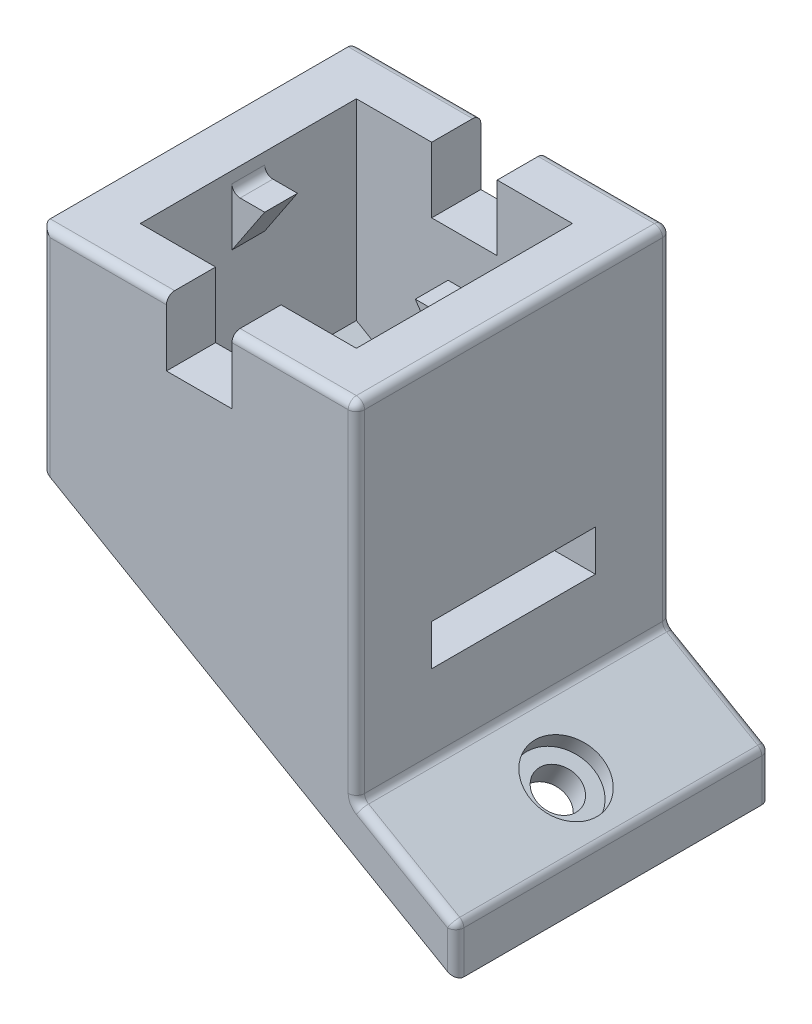
from build123d import *

# Parameters (mm, degrees)
SKETCH1_W           = 19.2
SKETCH1_H           = 19.2
SKETCH1_W_2         = 13.2
SKETCH1_H_2         = 13.2
BOSS_EXTRUDE1_DEPTH = 30
CUT_EXTRUDE1_DEPTH  = 30
BOSS_EXTRUDE2_DEPTH = 19.2
SKETCH4_R           = 1.28
CUT_EXTRUDE2_DEPTH  = 30
SKETCH5_R           = 2.18
CUT_EXTRUDE3_DEPTH  = 1
SKETCH6_W           = 10
SKETCH6_H           = 2.5
CUT_EXTRUDE4_DEPTH  = 3
BOSS_EXTRUDE3_DEPTH = 1
SKETCH8_W           = 4
SKETCH8_H           = 3
CUT_EXTRUDE5_DEPTH  = 4
FILLET1_R           = 0.5
FILLET2_R           = 0.5


with BuildPart() as part:
    # Sketch1 → Boss-Extrude1 (new body)
    with BuildSketch(Plane(origin=(0, 0, 0), x_dir=(1, 0, 0), z_dir=(0, 1, 0))):
        Rectangle(SKETCH1_W, SKETCH1_H)
        Rectangle(SKETCH1_W_2, SKETCH1_H_2, mode=Mode.SUBTRACT)
    extrude(amount=-BOSS_EXTRUDE1_DEPTH)

    # Sketch2 → Cut-Extrude1 (cut)
    with BuildSketch(Plane.XY.offset(9.6)):
        Polygon((-9.6, -30), (-9.6, -10), (25.041016151, -30), align=None)
    extrude(amount=-CUT_EXTRUDE1_DEPTH, mode=Mode.SUBTRACT)

    # Sketch3 → Boss-Extrude2 (add)
    with BuildSketch(Plane.XY.offset(9.6)):
        Polygon((-9.6, -10), (-9.6, -12.886751346), (15.662177826, -27.471876514), (15.662177826, -24.585125168), align=None)
    extrude(amount=-BOSS_EXTRUDE2_DEPTH)

    # Sketch4 → Cut-Extrude2 (cut)
    with BuildSketch(Plane(origin=(-6.730127019, -11.656921938, 0), x_dir=(0.866025404, -0.5, 0), z_dir=(0.5, 0.866025404, 0))):
        with Locations(Location((22.558741962, 0, 0), (0, 0, 180))):  # turned: the seam where the file's is
            Circle(SKETCH4_R)
    extrude(amount=-CUT_EXTRUDE2_DEPTH, mode=Mode.SUBTRACT)

    # Sketch5 → Cut-Extrude3 (cut)
    with BuildSketch(Plane(origin=(-6.730127019, -11.656921938, 0), x_dir=(0.866025404, -0.5, 0), z_dir=(0.5, 0.866025404, 0))):
        with Locations(Location((22.558741962, 0, 0), (0, 0, 180))):  # turned: the seam where the file's is
            Circle(SKETCH5_R)
    extrude(amount=-CUT_EXTRUDE3_DEPTH, mode=Mode.SUBTRACT)

    # Sketch6 → Cut-Extrude4 (cut)
    with BuildSketch(Plane(origin=(9.6, 0, 0), x_dir=(0, 0, -1), z_dir=(1, 0, 0))):
        with Locations((0, -15)):
            Rectangle(SKETCH6_W, SKETCH6_H)
    extrude(amount=-CUT_EXTRUDE4_DEPTH, mode=Mode.SUBTRACT)

    # Sketch7 → Boss-Extrude3 (add, symmetric)
    with BuildSketch(Plane.XY):
        Polygon((-6.6, -4.2), (-6.6, -1.2), (-4.6, -1.2), align=None)
        Polygon((6.6, -1.2), (4.6, -1.2), (6.6, -4.2), align=None)
    extrude(amount=BOSS_EXTRUDE3_DEPTH, both=True)

    # Sketch8 → Cut-Extrude5 (cut)
    with BuildSketch(Plane(origin=(0, 0, 0), x_dir=(1, 0, 0), z_dir=(0, 1, 0))):
        with Locations((0, 8.1)):
            Rectangle(SKETCH8_W, SKETCH8_H)
        with Locations((0, -8.1)):
            Rectangle(SKETCH8_W, SKETCH8_H)
    extrude(amount=-CUT_EXTRUDE5_DEPTH, mode=Mode.SUBTRACT)

    # Fillet1
    fillet1_edges = [part.edges().sort_by_distance(p)[0] for p in [
        (-6.6, -1.2, 0),
        (6.6, -1.2, 0),
    ]]
    fillet(fillet1_edges, radius=FILLET1_R)

    # Fillet2
    fillet2_edges = [part.edges().sort_by_distance(p)[0] for p in [
        (-5.8, 0, -9.6),
        (9.6, 0, 0),
        (-5.8, 0, 9.6),
        (5.8, 0, 9.6),
        (5.8, 0, -9.6),
        (-9.6, -6.443375673, 9.6),
        (9.6, -10.542562584, 9.6),
        (9.6, -10.542562584, -9.6),
        (-9.6, -6.443375673, -9.6),
        (9.6, -21.085125168, 0),
        (15.662177826, -24.585125168, 0),
        (12.631088913, -22.835125168, 9.6),
        (15.662177826, -26.028500841, 9.6),
        (12.631088913, -22.835125168, -9.6),
        (15.662177826, -26.028500841, -9.6),
    ]]
    fillet(fillet2_edges, radius=FILLET2_R)


solid = part.part
